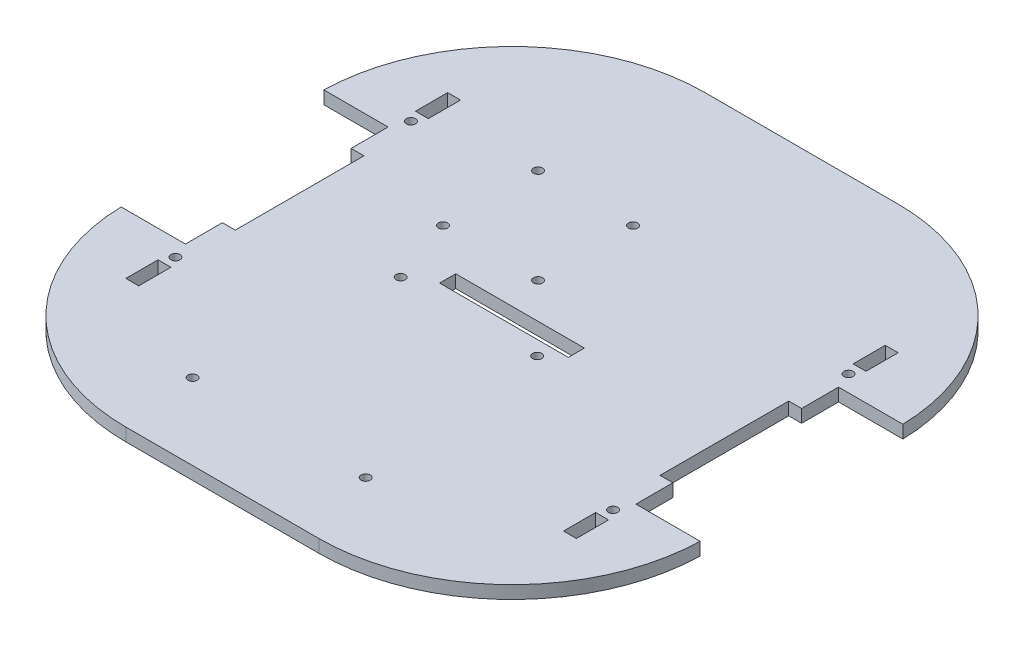
from build123d import *

# Parameters (mm, degrees)
SKETCH1_W                = 228.6
SKETCH1_H                = 228.6
BOSS_EXTRUDE1_DEPTH      = 5.08
SKETCH2_W                = 25.4
SKETCH2_H                = 80
CUT_EXTRUDE1_DEPTH       = 5.08
SKETCH3_W                = 5.08
SKETCH3_H                = 12.7
SKETCH3_H_2              = 50.8
CUT_EXTRUDE2_DEPTH       = 5.08
CUT_EXTRUDE4_DEPTH       = 5.08
MIRROR4_COPY_1_DEPTH     = 5.08
CUT_EXTRUDE6_REACH       = 7.08
SKETCH7_W                = 50.8
SKETCH7_H                = 6.35
M3_CLEARANCE_HOLE1_D     = 3.6
M3_CLEARANCE_HOLE1_DEPTH = 5.08
M3_CLEARANCE_HOLE2_D     = 3.6
M3_CLEARANCE_HOLE2_DEPTH = 5.08
SKETCH19_R               = 1.799999956
CUT_EXTRUDE7_DEPTH       = 5.08
MIRROR6_COPY_1_SKETCH_R  = 1.799999956
MIRROR6_COPY_1_DEPTH     = 5.08


with BuildPart() as part:
    # Sketch1 → Boss-Extrude1 (new body)
    with BuildSketch(Plane(origin=(0, 0, 0), x_dir=(1, 0, 0), z_dir=(0, 1, 0))):
        with Locations((114.3, 114.3)):
            Rectangle(SKETCH1_W, SKETCH1_H)
    extrude(amount=BOSS_EXTRUDE1_DEPTH)

    # Sketch2 → Cut-Extrude1 (cut)
    with BuildSketch(Plane(origin=(0, 5.08, 0), x_dir=(1, 0, 0), z_dir=(0, 1, 0))):
        with Locations((12.7, 114.3)):
            Rectangle(SKETCH2_W, SKETCH2_H)
    cut_extrude1 = extrude(amount=-CUT_EXTRUDE1_DEPTH, mode=Mode.SUBTRACT)

    # Mirror1: Cut-Extrude1 across plane
    add(cut_extrude1.mirror(Plane.ZY.offset(-114.3)), mode=Mode.SUBTRACT)

    # Sketch3 → Cut-Extrude2 (cut)
    with BuildSketch(Plane.XZ):
        with Locations((27.94, -171.45)):
            Rectangle(SKETCH3_W, SKETCH3_H)
        with Locations((27.94, -114.3)):
            Rectangle(SKETCH3_W, SKETCH3_H_2)
        with Locations((27.94, -57.15)):
            Rectangle(SKETCH3_W, SKETCH3_H)
    cut_extrude2 = extrude(amount=-CUT_EXTRUDE2_DEPTH, mode=Mode.SUBTRACT)

    # Mirror2: Cut-Extrude2 across plane
    add(cut_extrude2.mirror(Plane.ZY.offset(-114.3)), mode=Mode.SUBTRACT)

    # Sketch5 → Cut-Extrude4 (cut)
    with BuildSketch(Plane.XZ):
        with BuildLine():
            Line((0, -76.2), (0, 0))
            Line((0, 0), (76.2, 0))
            ThreePointArc((76.2, 0), (22.318463274, -22.318463274), (0, -76.2))
        make_face()
    cut_extrude4 = extrude(amount=-CUT_EXTRUDE4_DEPTH, mode=Mode.SUBTRACT)

    # Mirror3: Cut-Extrude4 across plane
    add(cut_extrude4.mirror(Plane.ZY.offset(-114.3)), mode=Mode.SUBTRACT)

    # Mirror4: Cut-Extrude4 across plane
    add(cut_extrude4.mirror(Plane.XY.offset(-114.3)), mode=Mode.SUBTRACT)

    # Mirror4 copy 1 sketch → Mirror4 copy 1 (cut)
    with BuildSketch(Plane(origin=(228.6, 0, -228.6), x_dir=(-1, 0, 0), z_dir=(0, -1, 0))):
        with BuildLine():
            Line((0, -76.2), (0, 0))
            Line((0, 0), (76.2, 0))
            ThreePointArc((76.2, 0), (22.318463274, -22.318463274), (0, -76.2))
        make_face()
    extrude(amount=-MIRROR4_COPY_1_DEPTH, mode=Mode.SUBTRACT)

    # Sketch7 → Cut-Extrude6 (cut, up to next)
    with BuildSketch(Plane(origin=(0, 5.08, 0), x_dir=(1, 0, 0), z_dir=(0, 1, 0)), mode=Mode.PRIVATE) as cut_extrude6_sk1:
        with Locations((114.3, 114.3)):
            Rectangle(SKETCH7_W, SKETCH7_H)
    cut_extrude6_tool1 = extrude(cut_extrude6_sk1.sketch, amount=-CUT_EXTRUDE6_REACH, mode=Mode.PRIVATE) & part.part
    add(cut_extrude6_tool1.solids().sort_by_distance((114.3, 5.08, -114.3))[0], mode=Mode.SUBTRACT)

    # M3 Clearance Hole1
    with Locations(Plane(origin=(0, 5.08, 0), x_dir=(1, 0, 0), z_dir=(0, 1, 0))):
        with Locations((107.41154214, 131.464372429), (107.41154214, 168.964372429), (69.91154214, 131.464372429), (69.91154214, 168.964372429)):
            Hole(M3_CLEARANCE_HOLE1_D / 2, depth=M3_CLEARANCE_HOLE1_DEPTH)

    # M3 Clearance Hole2
    with Locations(Plane(origin=(0, 5.08, 0), x_dir=(1, 0, 0), z_dir=(0, 1, 0))):
        with Locations((72.49651655, 30.046201608), (140.79651655, 30.046201608), (79.19651655, 105.446201608), (133.08651655, 105.446201608)):
            Hole(M3_CLEARANCE_HOLE2_D / 2, depth=M3_CLEARANCE_HOLE2_DEPTH)

    # Sketch19 → Cut-Extrude7 (cut)
    with BuildSketch(Plane.XZ):
        with Locations((200.66, -67.839999956)):
            Circle(SKETCH19_R)
    cut_extrude7 = extrude(amount=-CUT_EXTRUDE7_DEPTH, mode=Mode.SUBTRACT)

    # Mirror5: Cut-Extrude7 across plane
    add(cut_extrude7.mirror(Plane.XY.offset(-114.3)), mode=Mode.SUBTRACT)

    # Mirror6: Cut-Extrude7 across plane
    add(cut_extrude7.mirror(Plane.ZY.offset(-114.3)), mode=Mode.SUBTRACT)

    # Mirror6 copy 1 sketch → Mirror6 copy 1 (cut)
    with BuildSketch(Plane(origin=(228.6, 0, -228.6), x_dir=(-1, 0, 0), z_dir=(0, -1, 0))):
        with Locations((200.66, -67.839999956)):
            Circle(MIRROR6_COPY_1_SKETCH_R)
    extrude(amount=-MIRROR6_COPY_1_DEPTH, mode=Mode.SUBTRACT)


solid = part.part
